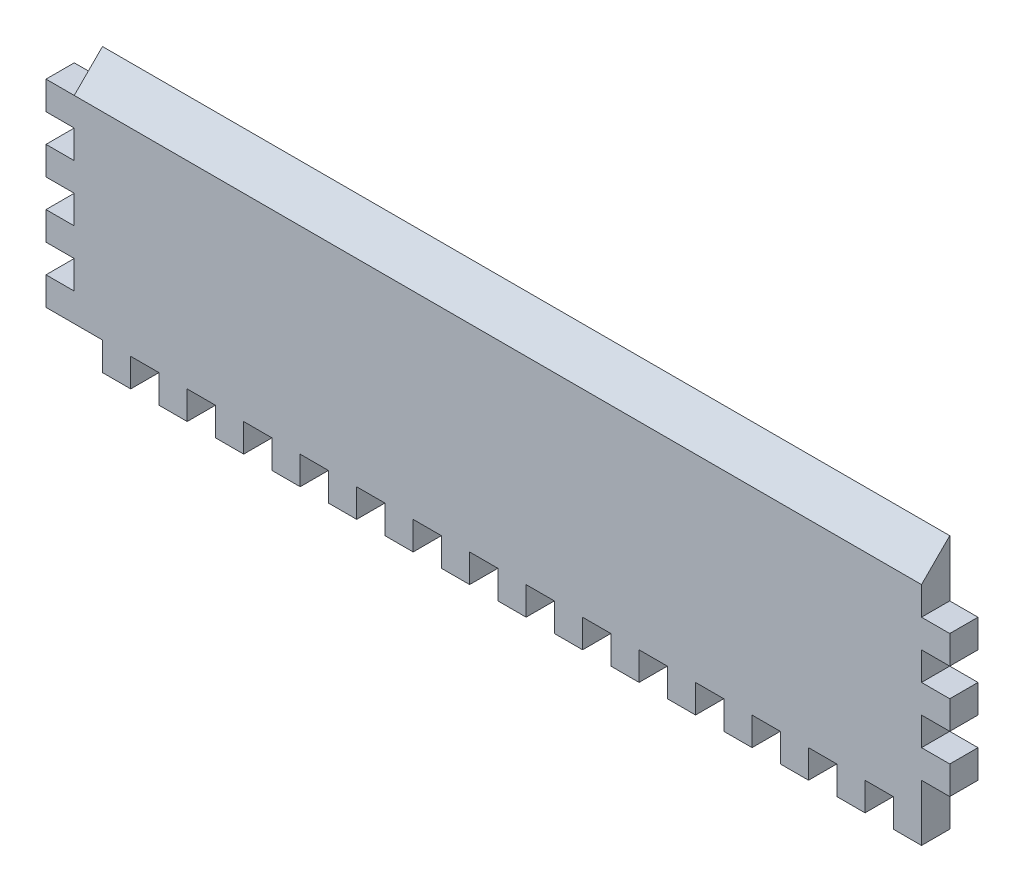
from build123d import *

# Parameters (mm, degrees)
SKETCH2_W           = 203.2
SKETCH2_H           = 57.15
BOSS_EXTRUDE1_DEPTH = 6.35
SKETCH3_W           = 12.7
SKETCH3_H           = 6.35
CUT_EXTRUDE1_DEPTH  = 6.35
SKETCH5_W           = 6.35
SKETCH5_H           = 6.35
CUT_EXTRUDE2_DEPTH  = 6.35
LPATTERN1_COUNT     = 15
LPATTERN1_PITCH     = 12.7
SKETCH6_W           = 6.35
SKETCH6_H           = 6.35
CUT_EXTRUDE3_DEPTH  = 6.35
SKETCH7_W           = 6.35
SKETCH7_H           = 6.35
CUT_EXTRUDE4_DEPTH  = 6.35
LPATTERN2_COUNT     = 4
LPATTERN2_PITCH     = 12.7
SKETCH8_W           = 6.35
SKETCH8_H           = 6.35
CUT_EXTRUDE5_DEPTH  = 6.35
SKETCH9_W           = 6.35
SKETCH9_H           = 6.35
CUT_EXTRUDE6_DEPTH  = 6.35
LPATTERN3_COUNT     = 4
LPATTERN3_PITCH     = 12.7
CUT_EXTRUDE7_DEPTH  = 190.5


with BuildPart() as part:
    # Sketch2 → Boss-Extrude1 (new body)
    with BuildSketch(Plane.XY):
        with Locations((101.6, 28.575)):
            Rectangle(SKETCH2_W, SKETCH2_H)
    extrude(amount=BOSS_EXTRUDE1_DEPTH)

    # Sketch3 → Cut-Extrude1 (cut)
    with BuildSketch(Plane.XZ):
        with Locations((6.35, 3.175)):
            Rectangle(SKETCH3_W, SKETCH3_H)
    extrude(amount=-CUT_EXTRUDE1_DEPTH, mode=Mode.SUBTRACT)

    # Sketch5 → Cut-Extrude2 (cut)
    with BuildSketch(Plane.XZ):
        with Locations((22.225, 3.175)):
            Rectangle(SKETCH5_W, SKETCH5_H)
    cut_extrude2 = extrude(amount=-CUT_EXTRUDE2_DEPTH, mode=Mode.SUBTRACT)

    # LPattern1: Cut-Extrude2 ×15
    with Locations(*[(i * LPATTERN1_PITCH, 0, 0) for i in range(1, LPATTERN1_COUNT)]):
        add(cut_extrude2, mode=Mode.SUBTRACT)

    # Sketch6 → Cut-Extrude3 (cut)
    with BuildSketch(Plane(origin=(203.2, 0, 0), x_dir=(0, 0, -1), z_dir=(1, 0, 0))):
        with Locations((-3.175, 9.525)):
            Rectangle(SKETCH6_W, SKETCH6_H)
    extrude(amount=-CUT_EXTRUDE3_DEPTH, mode=Mode.SUBTRACT)

    # Sketch7 → Cut-Extrude4 (cut)
    with BuildSketch(Plane(origin=(203.2, 0, 0), x_dir=(0, 0, -1), z_dir=(1, 0, 0))):
        with Locations((-3.175, 22.225)):
            Rectangle(SKETCH7_W, SKETCH7_H)
    cut_extrude4 = extrude(amount=-CUT_EXTRUDE4_DEPTH, mode=Mode.SUBTRACT)

    # LPattern2: Cut-Extrude4 ×4
    with Locations(*[(0, i * LPATTERN2_PITCH, 0) for i in range(1, LPATTERN2_COUNT)]):
        add(cut_extrude4, mode=Mode.SUBTRACT)

    # Sketch8 → Cut-Extrude5 (cut)
    with BuildSketch(Plane(origin=(203.2, 0, 0), x_dir=(0, 0, -1), z_dir=(1, 0, 0))):
        with Locations((-3.175, 53.975)):
            Rectangle(SKETCH8_W, SKETCH8_H)
    extrude(amount=-CUT_EXTRUDE5_DEPTH, mode=Mode.SUBTRACT)

    # Sketch9 → Cut-Extrude6 (cut)
    with BuildSketch(Plane.ZY):
        with Locations((3.175, 15.875)):
            Rectangle(SKETCH9_W, SKETCH9_H)
    cut_extrude6 = extrude(amount=-CUT_EXTRUDE6_DEPTH, mode=Mode.SUBTRACT)

    # LPattern3: Cut-Extrude6 ×4
    with Locations(*[(0, i * LPATTERN3_PITCH, 0) for i in range(1, LPATTERN3_COUNT)]):
        add(cut_extrude6, mode=Mode.SUBTRACT)

    # Sketch10 → Cut-Extrude7 (cut)
    with BuildSketch(Plane.ZY.offset(-6.35)):
        Polygon((6.35, 57.15), (6.35, 50.8), (0, 57.15), align=None)
    extrude(amount=-CUT_EXTRUDE7_DEPTH, mode=Mode.SUBTRACT)


solid = part.part
